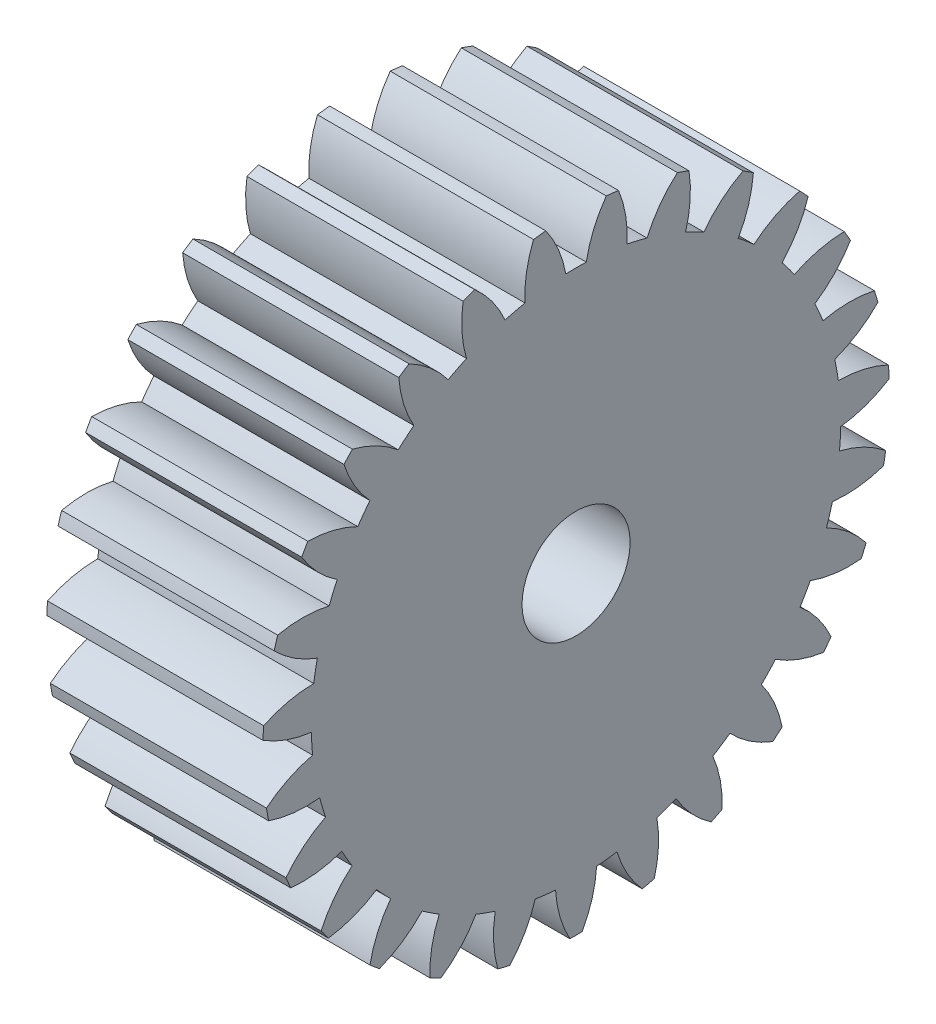
from build123d import *

# Parameters (mm, degrees)
BASPROSKE_W     = 10
BASPROSKE_H     = 14.5
TOOTHCUT_DEPTH  = 23.814469093
TEETHCUTS_COUNT = 27
TEETHCUTS_ANGLE = 346.666666667
BORSKE_R        = 2.5
BORE_DEPTH      = 50.0000508


with BuildPart() as part:
    # BasProSke → Base-Revolve (revolve)
    with BuildSketch(Plane(origin=(0, 0, 0), x_dir=(1, 0, 0), z_dir=(0, 1, 0)), mode=Mode.PRIVATE) as base_revolve_sk:
        with Locations((5, 7.25)):
            Rectangle(BASPROSKE_W, BASPROSKE_H)
    revolve(base_revolve_sk.sketch.rotate(Axis((-10, 0, 0), (1, 0, 0)), 180), axis=Axis((-10, 0, 0), (1, 0, 0)))

    # TooCutSke → ToothCut (cut, through all)
    with BuildSketch(Plane(origin=(0, 0, 0), x_dir=(0, 0, -1), z_dir=(1, 0, 0))):
        with BuildLine():
            ThreePointArc((0.474054864, 12.239823242), (0, 12.249), (-0.474054864, 12.239823242))
            ThreePointArc((-0.474054864, 12.239823242), (-0.820231692, 13.40120918), (-1.416685779, 14.456149092))
            ThreePointArc((-1.416685779, 14.456149092), (0, 14.5254), (1.416685779, 14.456149092))
            ThreePointArc((1.416685779, 14.456149092), (0.820231692, 13.40120918), (0.474054864, 12.239823242))
        make_face()
    toothcut = extrude(amount=TOOTHCUT_DEPTH, mode=Mode.SUBTRACT)

    # TeethCuts: ToothCut ×27 about axis
    teethcuts_axis = Axis((-10, 0, 0), (1, 0, 0))
    for i in range(1, TEETHCUTS_COUNT):
        add(toothcut.rotate(teethcuts_axis, i * TEETHCUTS_ANGLE / (TEETHCUTS_COUNT - 1)), mode=Mode.SUBTRACT)

    # BorSke → Bore (cut, symmetric)
    with BuildSketch(Plane(origin=(0, 0, 0), x_dir=(0, 0, -1), z_dir=(1, 0, 0))):
        with Locations(Location((0, 0, 0), (0, 0, 180))):
            Circle(BORSKE_R)
    extrude(amount=BORE_DEPTH, both=True, mode=Mode.SUBTRACT)


solid = part.part
